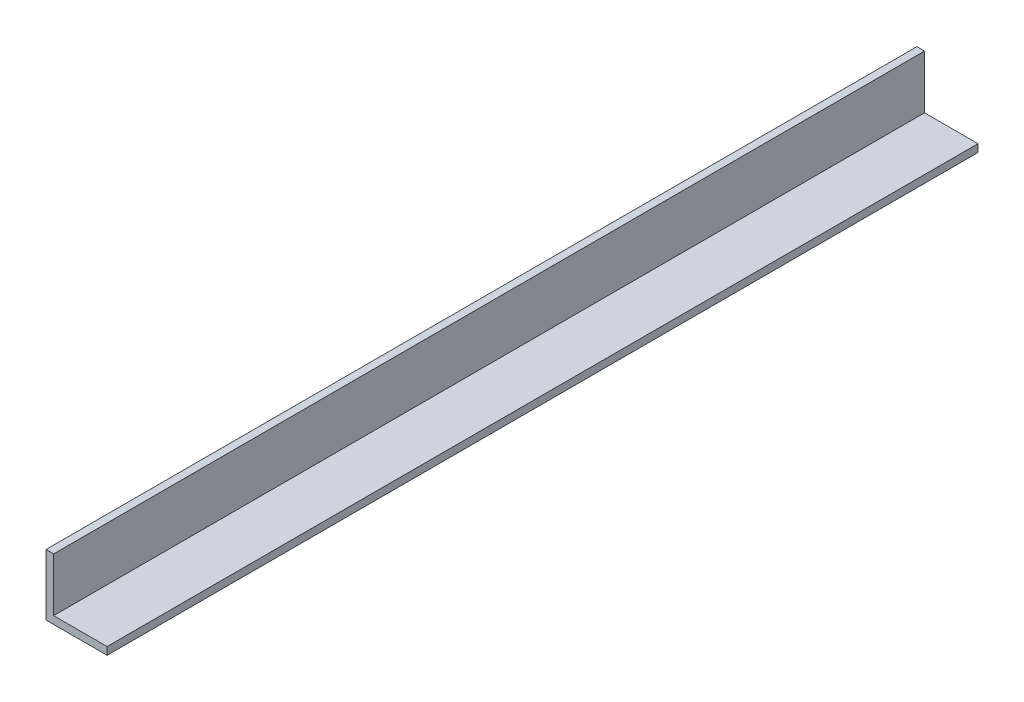
from build123d import *

# Parameters (mm, degrees)
BOSS_EXTRUDE1_DEPTH = 180.975


with BuildPart() as part:
    # Sketch1 → Boss-Extrude1 (new body, symmetric)
    with BuildSketch(Plane.XY):
        Polygon((0, 25.4), (0, 0), (25.4, 0), (25.4, 3.175), (3.175, 3.175), (3.175, 25.4), align=None)
    extrude(amount=BOSS_EXTRUDE1_DEPTH, both=True)


solid = part.part
